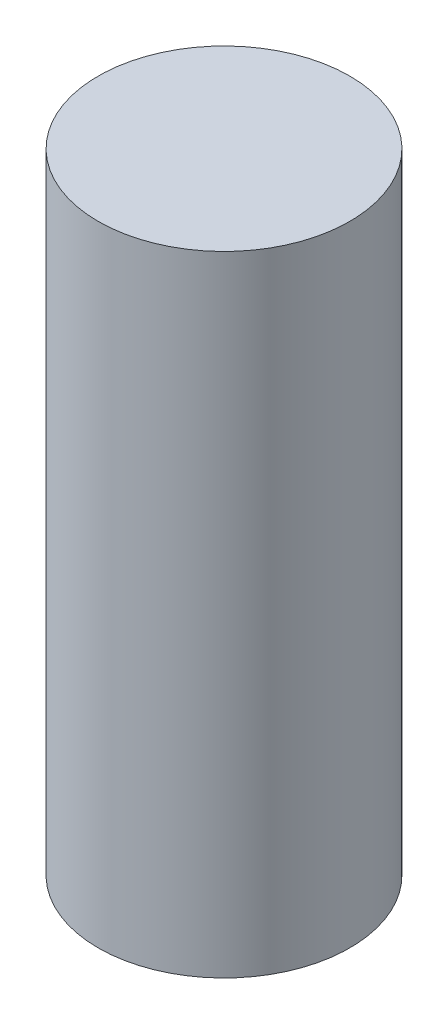
from build123d import *

# Parameters (mm, degrees)
SKETCH1_W = 20
SKETCH1_H = 100


with BuildPart() as part:
    # Sketch1 → Revolve1 (revolve)
    with BuildSketch(Plane.XY, mode=Mode.PRIVATE) as revolve1_sk:
        with Locations((10, 50)):
            Rectangle(SKETCH1_W, SKETCH1_H)
    revolve(revolve1_sk.sketch.rotate(Axis((0, 0, 0), (0, 1, 0)), 90), axis=Axis((0, 0, 0), (0, 1, 0)))  # turned: the seam where the file's is


solid = part.part
